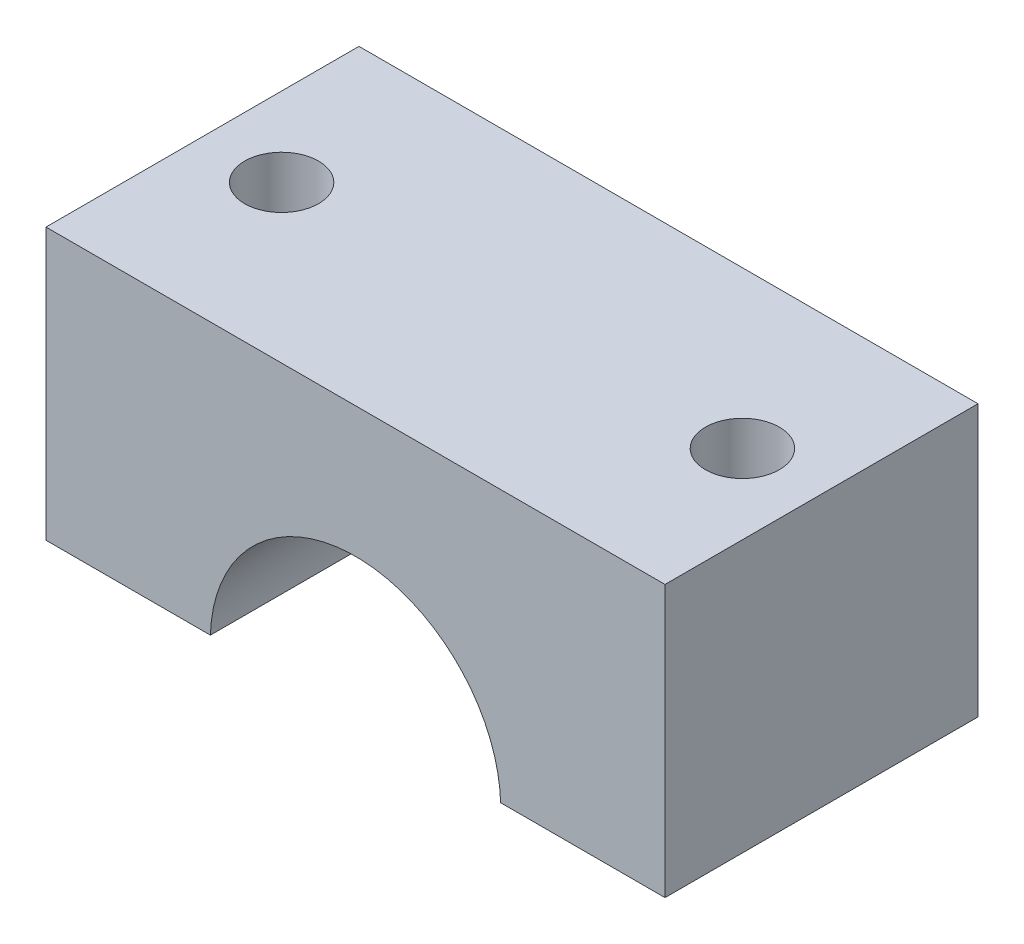
from build123d import *

# Parameters (mm, degrees)
BOSS_EXTRUDE1_DEPTH = 36
SKETCH2_R           = 4.25
CUT_EXTRUDE1_DEPTH  = 32.7
SKETCH3_W           = 36
SKETCH3_H           = 0.5
CUT_EXTRUDE2_DEPTH  = 72.2


with BuildPart() as part:
    # Sketch1 → Boss-Extrude1 (new body)
    with BuildSketch(Plane.XY):
        with BuildLine():
            Line((-73.529829319, 33.051903281), (-144.729829319, 33.051903281))
            Line((-144.729829319, 33.051903281), (-144.729829319, 1.351903281))
            Line((-144.729829319, 1.351903281), (-125.829829319, 1.351903281))
            ThreePointArc((-125.829829319, 1.351903281), (-109.129829319, 18.051903281), (-92.429829319, 1.351903281))
            Line((-92.429829319, 1.351903281), (-73.529829319, 1.351903281))
            Line((-73.529829319, 1.351903281), (-73.529829319, 33.051903281))
        make_face()
    extrude(amount=BOSS_EXTRUDE1_DEPTH)

    # Sketch2 → Cut-Extrude1 (cut, through all)
    with BuildSketch(Plane(origin=(0, 33.051903281, 0), x_dir=(1, 0, 0), z_dir=(0, 1, 0))):
        with Locations((-82.628590119, -18)):
            Circle(SKETCH2_R)
        with Locations((-135.631068518, -18)):
            Circle(SKETCH2_R)
    extrude(amount=-CUT_EXTRUDE1_DEPTH, mode=Mode.SUBTRACT)

    # Sketch3 → Cut-Extrude2 (cut, through all)
    with BuildSketch(Plane.ZY.offset(144.729829319)):
        with Locations((18, 1.601903281)):
            Rectangle(SKETCH3_W, SKETCH3_H)
    extrude(amount=-CUT_EXTRUDE2_DEPTH, mode=Mode.SUBTRACT)


solid = part.part
